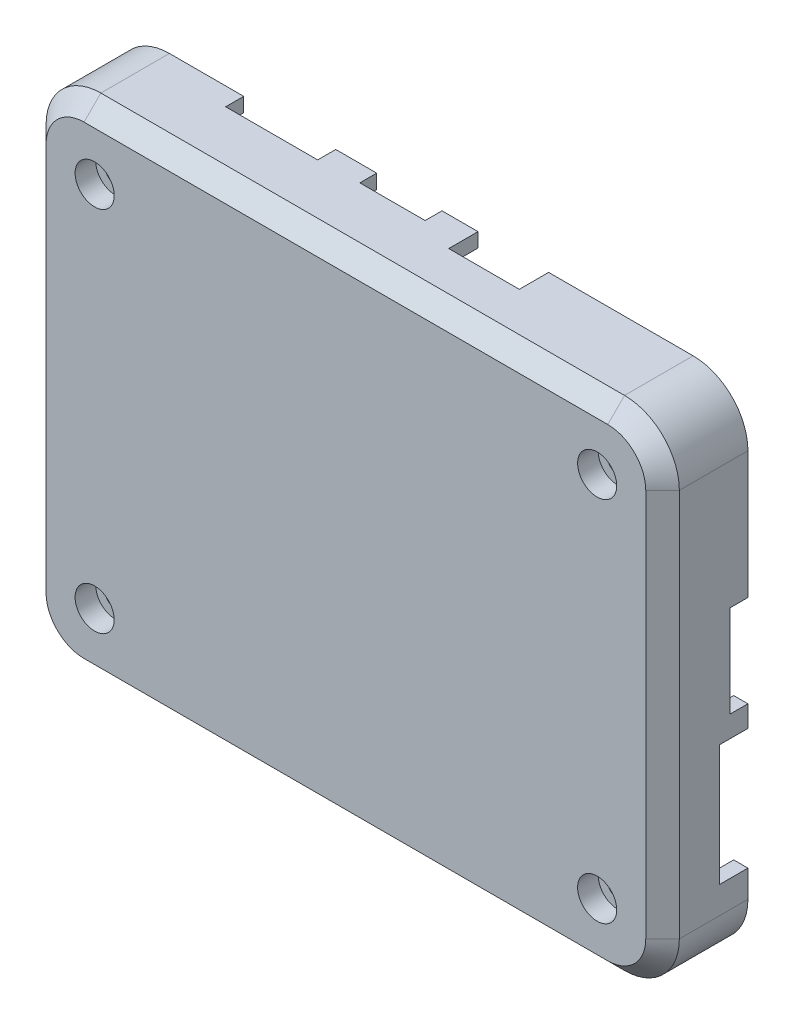
from build123d import *

# Parameters (mm, degrees)
SKETCH_1_W                     = 89
SKETCH_1_H                     = 70
EXTRUDE_1_DEPTH                = 12
FILLET_1_R                     = 7.7
CHAMFER_1_SIZE                 = 2.36
SHELL_1_T                      = -2
CUT_EXTRUDE_1_REACH            = 72
SKETCH_2_W                     = 9.92
SKETCH_2_H                     = 4.12
SKETCH_2_W_2                   = 9.17
SKETCH_2_H_2                   = 2.37
SKETCH_2_W_3                   = 12.93
SKETCH_2_H_3                   = 2.54
CUT_EXTRUDE_2_REACH            = 91
SKETCH_3_W                     = 2.54
SKETCH_3_H                     = 12.93
SKETCH_3_W_2                   = 4
SKETCH_3_H_2                   = 17
CUT_EXTRUDE_3_REACH            = 91
SKETCH_4_W                     = 2.54
SKETCH_4_H                     = 12.93
SKETCH_5_R                     = 4.5
EXTRUDE_2_DEPTH                = 10
HOLE_WIZARD_M2_5_1_D           = 2.9
HOLE_WIZARD_M2_5_1_CBORE_D     = 5.5
HOLE_WIZARD_M2_5_1_CBORE_DEPTH = 2.9


with BuildPart() as part:
    # 草圖1 → 填料-伸長1 (new body)
    with BuildSketch(Plane.XY):
        Rectangle(SKETCH_1_W, SKETCH_1_H)
    extrude(amount=EXTRUDE_1_DEPTH)

    # 圓角1
    fillet_1_edges = [part.edges().sort_by_distance(p)[0] for p in [
        (44.5, -35, 6),
        (-44.5, -35, 6),
        (-44.5, 35, 6),
        (44.5, 35, 6),
    ]]
    fillet(fillet_1_edges, radius=FILLET_1_R)

    # 導角1
    chamfer_1_edges = [part.edges().sort_by_distance(p)[0] for p in [
        (0, -35, 12),
        (-44.5, 0, 12),
        (44.5, 0, 12),
        (0, 35, 12),
        (-42.244722215, 32.744722215, 12),
        (42.244722215, 32.744722215, 12),
        (42.244722215, -32.744722215, 12),
        (-42.244722215, -32.744722215, 12),
    ]]
    chamfer(chamfer_1_edges, length=CHAMFER_1_SIZE)

    # 薄殼1
    shell_1_openings = [part.faces().sort_by_distance(p)[0] for p in [
        (0, 0, 0),
    ]]
    offset(amount=SHELL_1_T, openings=shell_1_openings, kind=Kind.INTERSECTION)

    # 草圖2 → 除料-伸長1 (cut, up to next)
    with BuildSketch(Plane(origin=(0, 35, 0), x_dir=(1, 0, 0), z_dir=(0, 1, 0)), mode=Mode.PRIVATE) as cut_extrude_1_sk1:
        with Locations((11.53, -2.06)):
            Rectangle(SKETCH_2_W, SKETCH_2_H)
    cut_extrude_1_tool1 = extrude(cut_extrude_1_sk1.sketch, amount=-CUT_EXTRUDE_1_REACH, mode=Mode.PRIVATE) & part.part
    add(cut_extrude_1_tool1.solids().sort_by_distance((11.53, 35, 2.06))[0], mode=Mode.SUBTRACT)
    # 草圖2 → 除料-伸長1 (cut, up to next)
    with BuildSketch(Plane(origin=(0, 35, 0), x_dir=(1, 0, 0), z_dir=(0, 1, 0)), mode=Mode.PRIVATE) as cut_extrude_1_sk2:
        with Locations((-3.085, -1.185)):
            Rectangle(SKETCH_2_W_2, SKETCH_2_H_2)
    cut_extrude_1_tool2 = extrude(cut_extrude_1_sk2.sketch, amount=-CUT_EXTRUDE_1_REACH, mode=Mode.PRIVATE) & part.part
    add(cut_extrude_1_tool2.solids().sort_by_distance((-3.085, 35, 1.185))[0], mode=Mode.SUBTRACT)
    # 草圖2 → 除料-伸長1 (cut, up to next)
    with BuildSketch(Plane(origin=(0, 35, 0), x_dir=(1, 0, 0), z_dir=(0, 1, 0)), mode=Mode.PRIVATE) as cut_extrude_1_sk3:
        with Locations((-19.895, -1.27)):
            Rectangle(SKETCH_2_W_3, SKETCH_2_H_3)
    cut_extrude_1_tool3 = extrude(cut_extrude_1_sk3.sketch, amount=-CUT_EXTRUDE_1_REACH, mode=Mode.PRIVATE) & part.part
    add(cut_extrude_1_tool3.solids().sort_by_distance((-19.895, 35, 1.27))[0], mode=Mode.SUBTRACT)

    # 草圖3 → 除料-伸長2 (cut, up to next)
    with BuildSketch(Plane(origin=(44.5, 0, 0), x_dir=(0, 0, -1), z_dir=(1, 0, 0)), mode=Mode.PRIVATE) as cut_extrude_2_sk1:
        with Locations((-1.27, 2.965)):
            Rectangle(SKETCH_3_W, SKETCH_3_H)
    cut_extrude_2_tool1 = extrude(cut_extrude_2_sk1.sketch, amount=-CUT_EXTRUDE_2_REACH, mode=Mode.PRIVATE) & part.part
    add(cut_extrude_2_tool1.solids().sort_by_distance((44.5, 2.965, 1.27))[0], mode=Mode.SUBTRACT)
    # 草圖3 → 除料-伸長2 (cut, up to next)
    with BuildSketch(Plane(origin=(44.5, 0, 0), x_dir=(0, 0, -1), z_dir=(1, 0, 0)), mode=Mode.PRIVATE) as cut_extrude_2_sk2:
        with Locations((-2, -15)):
            Rectangle(SKETCH_3_W_2, SKETCH_3_H_2)
    cut_extrude_2_tool2 = extrude(cut_extrude_2_sk2.sketch, amount=-CUT_EXTRUDE_2_REACH, mode=Mode.PRIVATE) & part.part
    add(cut_extrude_2_tool2.solids().sort_by_distance((44.5, -15, 2))[0], mode=Mode.SUBTRACT)

    # 草圖4 → 除料-伸長3 (cut, up to next)
    with BuildSketch(Plane.ZY.offset(44.5), mode=Mode.PRIVATE) as cut_extrude_3_sk1:
        with Locations((1.27, 1.535)):
            Rectangle(SKETCH_4_W, SKETCH_4_H)
    cut_extrude_3_tool1 = extrude(cut_extrude_3_sk1.sketch, amount=-CUT_EXTRUDE_3_REACH, mode=Mode.PRIVATE) & part.part
    add(cut_extrude_3_tool1.solids().sort_by_distance((-44.5, 1.535, 1.27))[0], mode=Mode.SUBTRACT)

    # 草圖5 → 填料-伸長2 (add)
    with BuildSketch(Plane(origin=(0, 0, 10), x_dir=(-1, 0, 0), z_dir=(0, 0, -1))):
        with Locations((-35.311572875, 25.811572875)):
            Circle(SKETCH_5_R)
        with Locations((35.311572875, 25.811572875)):
            Circle(SKETCH_5_R)
        with Locations((35.311572875, -25.811572875)):
            Circle(SKETCH_5_R)
        with Locations((-35.311572875, -25.811572875)):
            Circle(SKETCH_5_R)
    extrude(amount=EXTRUDE_2_DEPTH)

    # M2.5 六角承窩頭蓋螺釘的柱孔1 (through all)
    with Locations(Plane(origin=(35.311572875, -25.811572875, 12), x_dir=(1, 0, 0), z_dir=(0, 0, 1))):
        with Locations((0, 0), (-70.62314575, 0), (-70.62314575, 51.62314575), (0, 51.62314575)):
            CounterBoreHole(HOLE_WIZARD_M2_5_1_D / 2, HOLE_WIZARD_M2_5_1_CBORE_D / 2, HOLE_WIZARD_M2_5_1_CBORE_DEPTH)


solid = part.part
